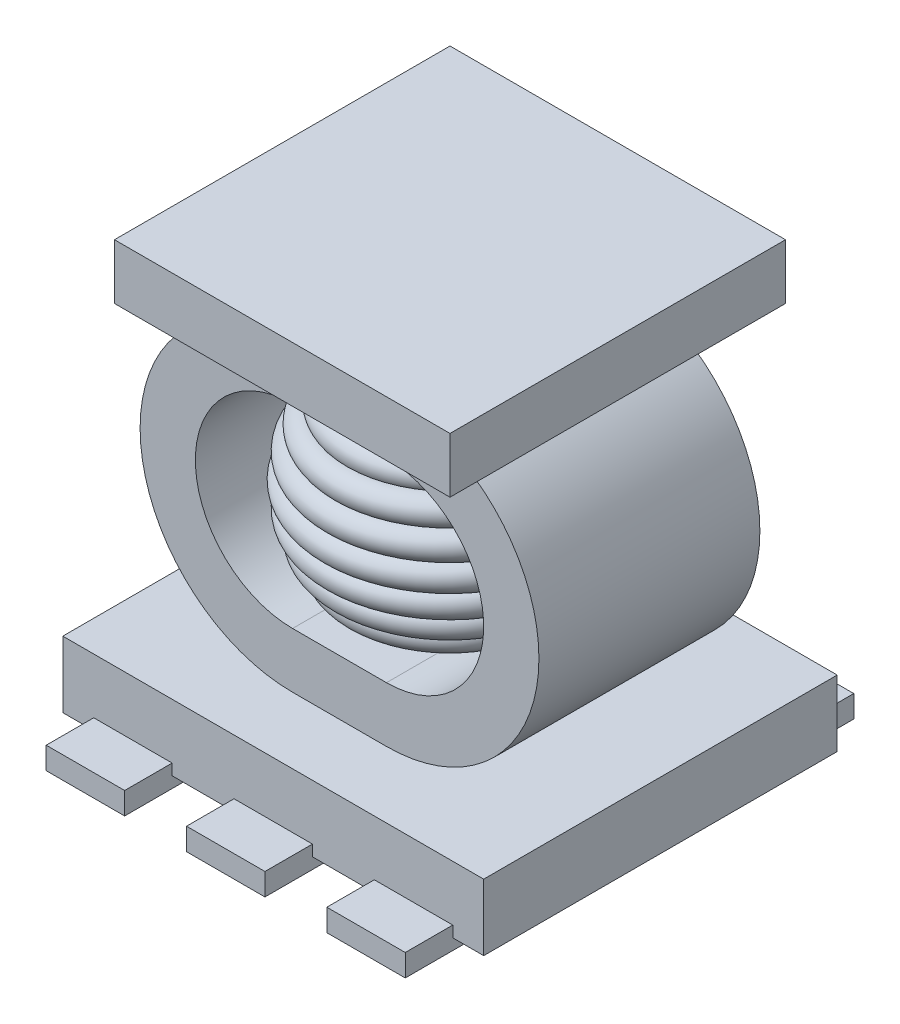
from build123d import *

# Parameters (mm, degrees)
SKETCH1_W           = 3.81
SKETCH1_H           = 3.2
BOSS_EXTRUDE1_DEPTH = 0.6
SKETCH2_W           = 0.71
SKETCH2_H           = 0.93
BOSS_EXTRUDE2_DEPTH = 0.1
BOSS_EXTRUDE3_DEPTH = 1
SKETCH6_W           = 3.037044722
SKETCH6_H           = 3.037044722
BOSS_EXTRUDE4_DEPTH = 0.5


with BuildPart() as part:
    # Sketch1 → Boss-Extrude1 (new body)
    with BuildSketch(Plane(origin=(0, 0, 0), x_dir=(1, 0, 0), z_dir=(0, 1, 0))):
        Rectangle(SKETCH1_W, SKETCH1_H)
    extrude(amount=BOSS_EXTRUDE1_DEPTH)

    # Sketch2 → Boss-Extrude2 (add, symmetric)
    with BuildSketch(Plane.XZ):
        with Locations((0, 1.565)):
            Rectangle(SKETCH2_W, SKETCH2_H)
        with Locations((1.27, 1.565)):
            Rectangle(SKETCH2_W, SKETCH2_H)
        with Locations((-1.27, 1.565)):
            Rectangle(SKETCH2_W, SKETCH2_H)
        with Locations((-1.27, -1.565)):
            Rectangle(SKETCH2_W, SKETCH2_H)
        with Locations((0, -1.565)):
            Rectangle(SKETCH2_W, SKETCH2_H)
        with Locations((1.27, -1.565)):
            Rectangle(SKETCH2_W, SKETCH2_H)
    extrude(amount=BOSS_EXTRUDE2_DEPTH, both=True)

    # Sketch3 → Boss-Extrude3 (add, symmetric)
    with BuildSketch(Plane.XY):
        with BuildLine():
            Line((0.425, 0.6), (-0.425, 0.6))
            ThreePointArc((-0.425, 0.6), (-1.805, 1.98), (-0.425, 3.36))
            Line((-0.425, 3.36), (0.425, 3.36))
            ThreePointArc((0.425, 3.36), (1.805, 1.98), (0.425, 0.6))
        make_face()
        with BuildLine():
            Line((0.425, 1.1), (-0.425, 1.1))
            ThreePointArc((-0.425, 1.1), (-1.305, 1.98), (-0.425, 2.86))
            Line((-0.425, 2.86), (0.425, 2.86))
            ThreePointArc((0.425, 2.86), (1.305, 1.98), (0.425, 1.1))
        make_face(mode=Mode.SUBTRACT)
    extrude(amount=BOSS_EXTRUDE3_DEPTH, both=True)

    # Sketch4 → Revolve1 (revolve)
    with BuildSketch(Plane.XY):
        with BuildLine():
            Line((-0.564749258, 2.884412409), (-0.244079314, 2.884412409))
            Line((-0.244079314, 2.884412409), (-0.244079314, 2.86))
            Line((-0.244079314, 2.86), (0, 2.86))
            Line((0, 2.86), (0, 1.1))
            Line((0, 1.1), (-0.244079314, 1.1))
            Line((-0.244079314, 1.1), (-0.244079314, 1.075587591))
            Line((-0.244079314, 1.075587591), (-0.564749258, 1.075587591))
            ThreePointArc((-0.564749258, 1.075587591), (-0.676106899, 1.147042688), (-0.777430888, 1.232129728))
            ThreePointArc((-0.777430888, 1.232129728), (-0.915343808, 1.272513751), (-0.929643812, 1.415504494))
            ThreePointArc((-0.929643812, 1.415504494), (-1.054652094, 1.486383069), (-1.035843582, 1.628850899))
            ThreePointArc((-1.035843582, 1.628850899), (-1.141309966, 1.726460758), (-1.090391567, 1.860841409))
            ThreePointArc((-1.090391567, 1.860841409), (-1.170716363, 1.98), (-1.090391567, 2.099158591))
            ThreePointArc((-1.090391567, 2.099158591), (-1.141309966, 2.233539242), (-1.035843582, 2.331149101))
            ThreePointArc((-1.035843582, 2.331149101), (-1.054652094, 2.473616931), (-0.929643812, 2.544495506))
            ThreePointArc((-0.929643812, 2.544495506), (-0.915343808, 2.687486249), (-0.777430888, 2.727870272))
            ThreePointArc((-0.777430888, 2.727870272), (-0.676106899, 2.812957312), (-0.564749258, 2.884412409))
        make_face()
    revolve(axis=Axis((0, 2.86, 0), (0, -1, 0)))

    # Sketch6 → Boss-Extrude4 (add)
    with BuildSketch(Plane(origin=(0, 3.36, 0), x_dir=(1, 0, 0), z_dir=(0, 1, 0))):
        Rectangle(SKETCH6_W, SKETCH6_H)
    extrude(amount=BOSS_EXTRUDE4_DEPTH)


solid = part.part
